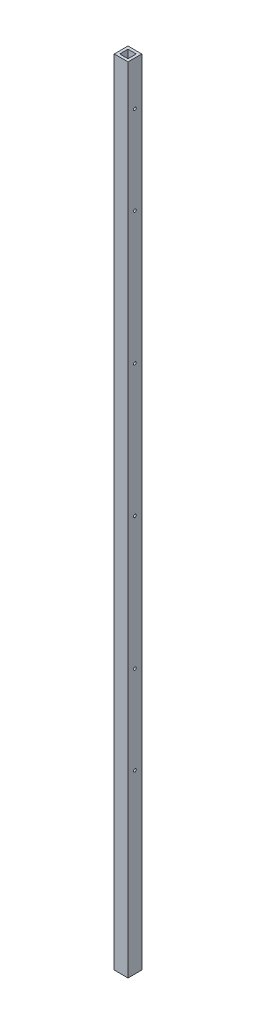
from build123d import *

# Parameters (mm, degrees)
SKETCH1_W           = 31.75
SKETCH1_H           = 31.75
BOSS_EXTRUDE1_DEPTH = 1828.8
SKETCH2_W           = 19.05
SKETCH2_H           = 19.05
CUT_EXTRUDE1_DEPTH  = 1829.8
SKETCH3_R           = 3.175
CUT_EXTRUDE2_DEPTH  = 32.75
SKETCH4_R           = 3.175
CUT_EXTRUDE3_DEPTH  = 32.75


with BuildPart() as part:
    # Sketch1 → Boss-Extrude1 (new body)
    with BuildSketch(Plane(origin=(0, 0, 0), x_dir=(1, 0, 0), z_dir=(0, 1, 0))):
        with Locations((15.875, 15.875)):
            Rectangle(SKETCH1_W, SKETCH1_H)
    extrude(amount=BOSS_EXTRUDE1_DEPTH)

    # Sketch2 → Cut-Extrude1 (cut, through all)
    with BuildSketch(Plane(origin=(0, 1828.8, 0), x_dir=(1, 0, 0), z_dir=(0, 1, 0))):
        with Locations((15.875, 15.875)):
            Rectangle(SKETCH2_W, SKETCH2_H)
    extrude(amount=-CUT_EXTRUDE1_DEPTH, mode=Mode.SUBTRACT)

    # Sketch3 → Cut-Extrude2 (cut, through all)
    with BuildSketch(Plane(origin=(31.75, 0, 0), x_dir=(0, 0, -1), z_dir=(1, 0, 0))):
        with Locations((15.875, 1727.2)):
            Circle(SKETCH3_R)
    extrude(amount=-CUT_EXTRUDE2_DEPTH, mode=Mode.SUBTRACT)

    # Sketch4 → Cut-Extrude3 (cut, through all)
    with BuildSketch(Plane(origin=(31.75, 0, 0), x_dir=(0, 0, -1), z_dir=(1, 0, 0))):
        with Locations((15.875, 1524)):
            Circle(SKETCH4_R)
        with Locations((15.875, 1219.2)):
            Circle(SKETCH4_R)
        with Locations((15.875, 914.4)):
            Circle(SKETCH4_R)
        with Locations((15.875, 609.6)):
            Circle(SKETCH4_R)
        with Locations((15.875, 406.4)):
            Circle(SKETCH4_R)
    extrude(amount=-CUT_EXTRUDE3_DEPTH, mode=Mode.SUBTRACT)


solid = part.part
